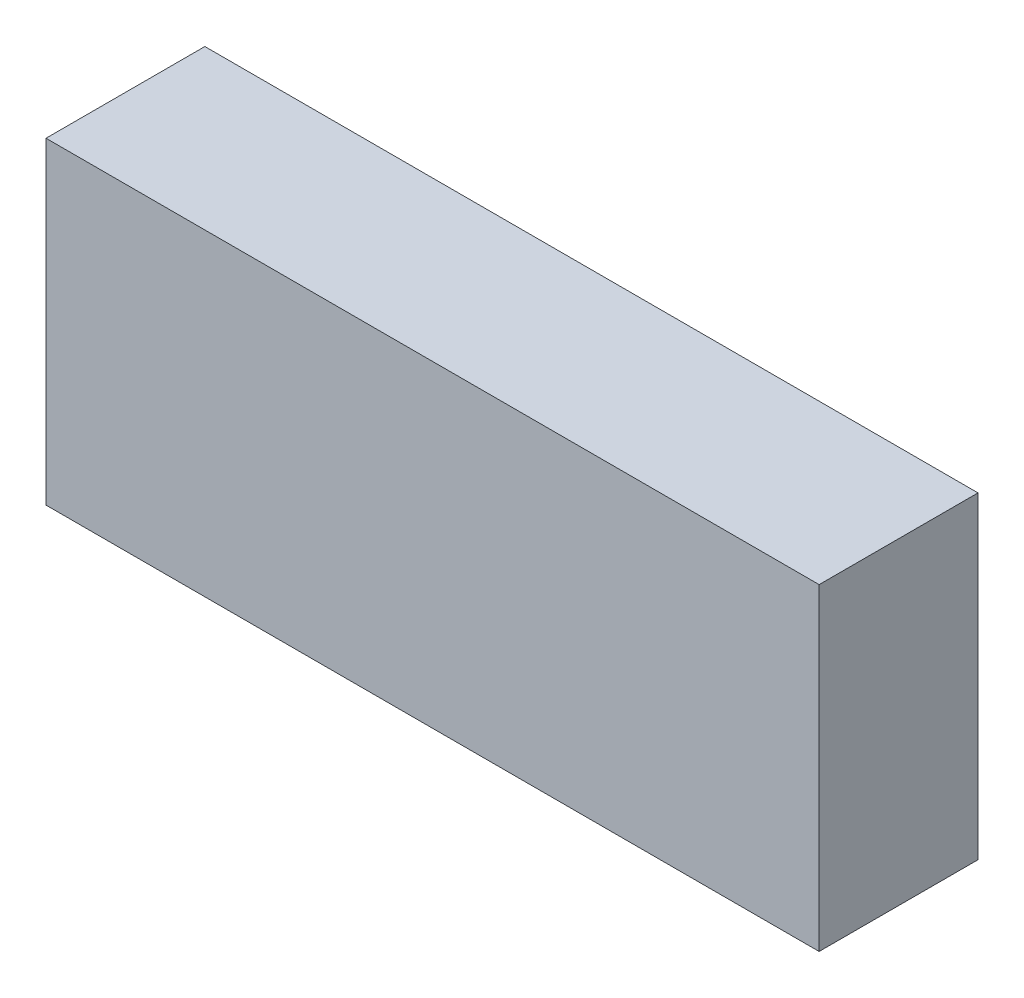
from build123d import *

# Parameters (mm, degrees)
SKETCH1_W           = 73
SKETCH1_H           = 30
BOSS_EXTRUDE1_DEPTH = 15


with BuildPart() as part:
    # Sketch1 → Boss-Extrude1 (new body)
    with BuildSketch(Plane.XY):
        with Locations((36.5, 15)):
            Rectangle(SKETCH1_W, SKETCH1_H)
    extrude(amount=BOSS_EXTRUDE1_DEPTH)


solid = part.part
